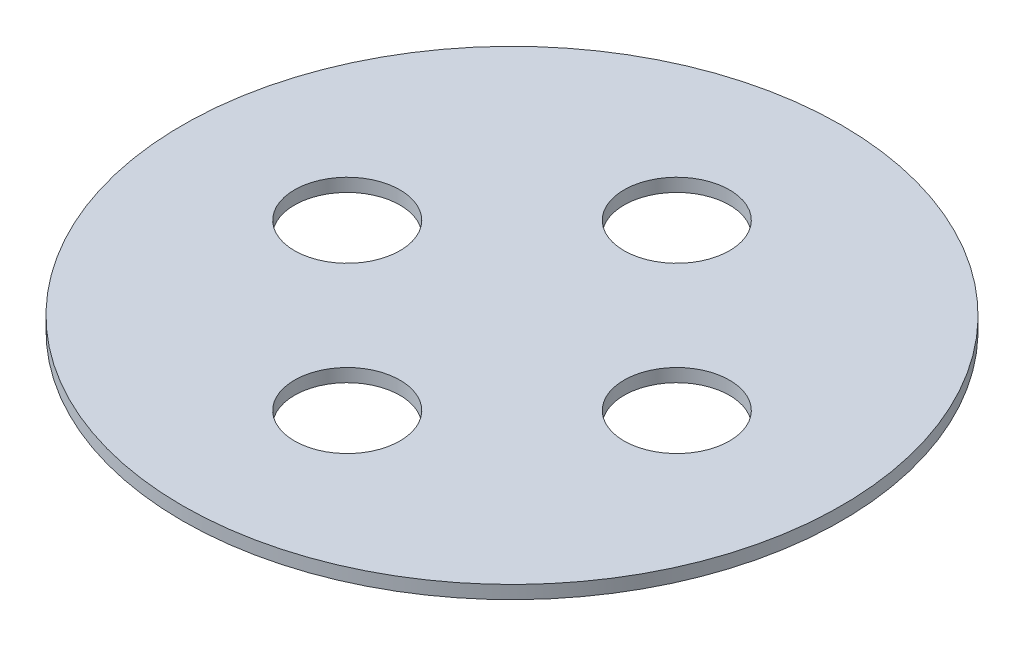
from build123d import *

# Parameters (mm, degrees)
SKETCH1_R           = 25
BOSS_EXTRUDE1_DEPTH = 1
SKETCH2_R           = 4
CUT_EXTRUDE1_DEPTH  = 1


with BuildPart() as part:
    # Sketch1 → Boss-Extrude1 (new body)
    with BuildSketch(Plane(origin=(0, 0, 0), x_dir=(1, 0, 0), z_dir=(0, 1, 0))):
        Circle(SKETCH1_R)
    extrude(amount=BOSS_EXTRUDE1_DEPTH)

    # Sketch2 → Cut-Extrude1 (cut)
    with BuildSketch(Plane(origin=(0, 1, 0), x_dir=(1, 0, 0), z_dir=(0, 1, 0))):
        with Locations((0, 12.5)):
            Circle(SKETCH2_R)
        with Locations((12.5, 0)):
            Circle(SKETCH2_R)
        with Locations((-12.5, 0)):
            Circle(SKETCH2_R)
        with Locations((0, -12.5)):
            Circle(SKETCH2_R)
    extrude(amount=-CUT_EXTRUDE1_DEPTH, mode=Mode.SUBTRACT)


solid = part.part
